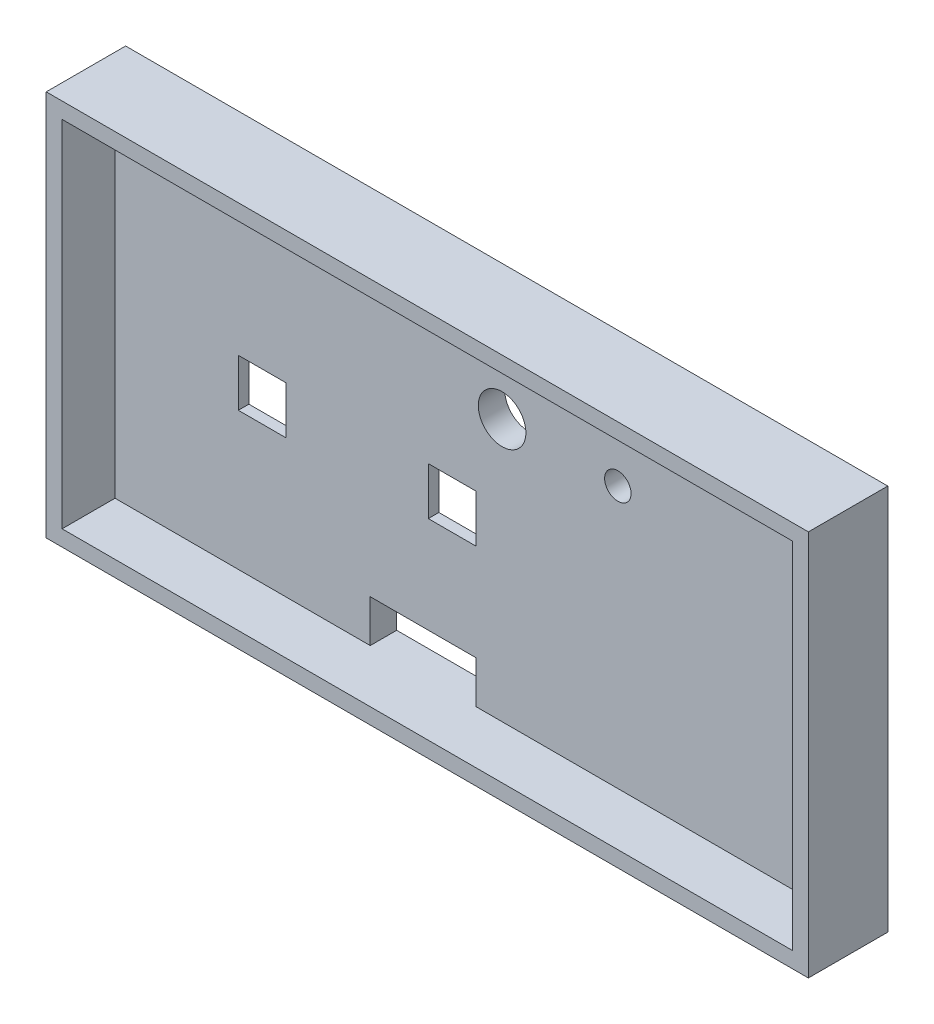
from build123d import *

# Parameters (mm, degrees)
ESQUISSE1_W              = 137
ESQUISSE1_H              = 66
BOSS_EXTRU_2_DEPTH       = 15
ESQUISSE3_W              = 131
ESQUISSE3_H              = 60
ENL_V_MAT_EXTRU_1_DEPTH  = 10
ESQUISSE5_W              = 12
ESQUISSE5_H              = 12
ENL_V_MAT_EXTRU_2_DEPTH  = 10
ESQUISSE6_W              = 12
ESQUISSE6_H              = 12
ENL_V_MAT_EXTRU_3_DEPTH  = 10
ESQUISSE7_W              = 15
ESQUISSE7_H              = 3
ENL_V_MAT_EXTRU_4_DEPTH  = 10
ESQUISSE8_R              = 4.5
ENL_V_MAT_EXTRU_5_DEPTH  = 10
ESQUISSE10_W             = 3
ESQUISSE10_H             = 8
BOSS_EXTRU_3_DEPTH       = 4
ESQUISSE12_W             = 2
ESQUISSE12_H             = 6
ENL_V_MAT_EXTRU_6_DEPTH  = 4
ESQUISSE13_W             = 3
ESQUISSE13_H             = 8
BOSS_EXTRU_4_DEPTH       = 4
ESQUISSE14_W             = 2
ESQUISSE14_H             = 6
ENL_V_MAT_EXTRU_7_DEPTH  = 4
ESQUISSE16_W             = 3
ESQUISSE16_H             = 8
BOSS_EXTRU_5_DEPTH       = 4
ESQUISSE17_W             = 3
ESQUISSE17_H             = 8
BOSS_EXTRU_6_DEPTH       = 4
ESQUISSE19_W             = 2
ESQUISSE19_H             = 6
ENL_V_MAT_EXTRU_9_DEPTH  = 3
ESQUISSE20_W             = 2
ESQUISSE20_H             = 6
ENL_V_MAT_EXTRU_10_DEPTH = 3
ESQUISSE21_R             = 1.5
ENL_V_MAT_EXTRU_12_DEPTH = 21
ESQUISSE22_W             = 3
ESQUISSE22_H             = 8
ENL_V_MAT_EXTRU_13_DEPTH = 4
ESQUISSE23_W             = 3
ESQUISSE23_H             = 8
ENL_V_MAT_EXTRU_14_DEPTH = 4
ESQUISSE24_W             = 3
ESQUISSE24_H             = 8
ENL_V_MAT_EXTRU_15_DEPTH = 4
ESQUISSE25_W             = 3
ESQUISSE25_H             = 8
ENL_V_MAT_EXTRU_16_DEPTH = 4
ESQUISSE28_W             = 12
ESQUISSE28_H             = 12
BOSS_EXTRU_7_DEPTH       = 5
ESQUISSE30_W             = 9
ESQUISSE30_H             = 9
ENL_V_MAT_EXTRU_17_DEPTH = 2.5
ESQUISSE32_W             = 9
ESQUISSE32_H             = 9
ENL_V_MAT_EXTRU_18_DEPTH = 8.5
ESQUISSE33_W             = 16
ESQUISSE33_H             = 16
ENL_V_MAT_EXTRU_19_DEPTH = 3
ESQUISSE34_W             = 16
ESQUISSE34_H             = 16
ENL_V_MAT_EXTRU_20_DEPTH = 3
ESQUISSE35_W             = 9
ESQUISSE35_H             = 9
ENL_V_MAT_EXTRU_21_DEPTH = 3
ESQUISSE36_W             = 12
ESQUISSE36_H             = 12
BOSS_EXTRU_8_DEPTH       = 5
ESQUISSE37_R             = 2.5
ENL_V_MAT_EXTRU_22_DEPTH = 5
ESQUISSE39_W             = 3
ESQUISSE39_H             = 60
ENL_V_MAT_EXTRU_23_DEPTH = 10
ESQUISSE40_W             = 5
ESQUISSE40_H             = 66
BOSS_EXTRU_9_DEPTH       = 7
ESQUISSE41_W             = 3
ESQUISSE41_H             = 66
BOSS_EXTRU_10_DEPTH      = 10
ESQUISSE42_W             = 4
ESQUISSE42_H             = 3
BOSS_EXTRU_11_DEPTH      = 10
ESQUISSE43_W             = 4
ESQUISSE43_H             = 3
BOSS_EXTRU_12_DEPTH      = 10
ESQUISSE44_W             = 20
ESQUISSE44_H             = 8
ENL_V_MAT_EXTRU_24_DEPTH = 10
ESQUISSE46_W             = 138
ESQUISSE46_H             = 3
ENL_V_MAT_EXTRU_25_DEPTH = 10
ESQUISSE47_W             = 141
ESQUISSE47_H             = 5
BOSS_EXTRU_13_DEPTH      = 7
ESQUISSE48_W             = 141
ESQUISSE48_H             = 3.004636282
BOSS_EXTRU_14_DEPTH      = 10
ESQUISSE49_W             = 3
ESQUISSE49_H             = 3.995363718
BOSS_EXTRU_15_DEPTH      = 10
ESQUISSE50_W             = 3
ESQUISSE50_H             = 15
BOSS_EXTRU_16_DEPTH      = 7


with BuildPart() as part:
    # Esquisse1 → Boss.-Extru.2 (new body)
    with BuildSketch(Plane.XY):
        with Locations((68.5, 33)):
            Rectangle(ESQUISSE1_W, ESQUISSE1_H)
    extrude(amount=BOSS_EXTRU_2_DEPTH)

    # Esquisse3 → Enlèv. mat.-Extru.1 (cut)
    with BuildSketch(Plane.XY.offset(15)):
        with Locations((68.5, 33)):
            Rectangle(ESQUISSE3_W, ESQUISSE3_H)
    extrude(amount=-ENL_V_MAT_EXTRU_1_DEPTH, mode=Mode.SUBTRACT)

    # Esquisse5 → Enlèv. mat.-Extru.2 (cut)
    with BuildSketch(Plane(origin=(0, 0, 0), x_dir=(-1, 0, 0), z_dir=(0, 0, -1))):
        with Locations((-14.887820014, 52.506524993)):
            Rectangle(ESQUISSE5_W, ESQUISSE5_H)
    extrude(amount=-ENL_V_MAT_EXTRU_2_DEPTH, mode=Mode.SUBTRACT)

    # Esquisse6 → Enlèv. mat.-Extru.3 (cut)
    with BuildSketch(Plane(origin=(0, 0, 0), x_dir=(-1, 0, 0), z_dir=(0, 0, -1))):
        with Locations((-42.758546676, 52.506524993)):
            Rectangle(ESQUISSE6_W, ESQUISSE6_H)
    extrude(amount=-ENL_V_MAT_EXTRU_3_DEPTH, mode=Mode.SUBTRACT)

    # Esquisse7 → Enlèv. mat.-Extru.4 (cut)
    with BuildSketch(Plane(origin=(0, 0, 0), x_dir=(-1, 0, 0), z_dir=(0, 0, -1))):
        with Locations((-55.331883335, 4.5)):
            Rectangle(ESQUISSE7_W, ESQUISSE7_H)
    extrude(amount=-ENL_V_MAT_EXTRU_4_DEPTH, mode=Mode.SUBTRACT)

    # Esquisse8 → Enlèv. mat.-Extru.5 (cut)
    with BuildSketch(Plane(origin=(0, 0, 0), x_dir=(-1, 0, 0), z_dir=(0, 0, -1))):
        with Locations((-69.128546676, 52.506524993)):
            Circle(ESQUISSE8_R)
    extrude(amount=-ENL_V_MAT_EXTRU_5_DEPTH, mode=Mode.SUBTRACT)

    # Esquisse10 → Boss.-Extru.3 (add)
    with BuildSketch(Plane.XY.offset(5)):
        with Locations((7.387820014, 52.506524993)):
            Rectangle(ESQUISSE10_W, ESQUISSE10_H)
    extrude(amount=BOSS_EXTRU_3_DEPTH)

    # Esquisse12 → Enlèv. mat.-Extru.6 (cut)
    with BuildSketch(Plane(origin=(8.887820014, 0, 0), x_dir=(0, 0, -1), z_dir=(1, 0, 0))):
        with Locations((-7, 52.506524993)):
            Rectangle(ESQUISSE12_W, ESQUISSE12_H)
    extrude(amount=-ENL_V_MAT_EXTRU_6_DEPTH, mode=Mode.SUBTRACT)

    # Esquisse13 → Boss.-Extru.4 (add)
    with BuildSketch(Plane.XY.offset(5)):
        with Locations((22.387820014, 52.506524993)):
            Rectangle(ESQUISSE13_W, ESQUISSE13_H)
    extrude(amount=BOSS_EXTRU_4_DEPTH)

    # Esquisse14 → Enlèv. mat.-Extru.7 (cut)
    with BuildSketch(Plane(origin=(23.887820014, 0, 0), x_dir=(0, 0, -1), z_dir=(1, 0, 0))):
        with Locations((-7, 52.506524993)):
            Rectangle(ESQUISSE14_W, ESQUISSE14_H)
    extrude(amount=-ENL_V_MAT_EXTRU_7_DEPTH, mode=Mode.SUBTRACT)

    # Esquisse16 → Boss.-Extru.5 (add)
    with BuildSketch(Plane.XY.offset(5)):
        with Locations((35.258546676, 52.506524993)):
            Rectangle(ESQUISSE16_W, ESQUISSE16_H)
    extrude(amount=BOSS_EXTRU_5_DEPTH)

    # Esquisse17 → Boss.-Extru.6 (add)
    with BuildSketch(Plane.XY.offset(5)):
        with Locations((50.258546676, 52.506524993)):
            Rectangle(ESQUISSE17_W, ESQUISSE17_H)
    extrude(amount=BOSS_EXTRU_6_DEPTH)

    # Esquisse19 → Enlèv. mat.-Extru.9 (cut)
    with BuildSketch(Plane(origin=(36.758546676, 0, 0), x_dir=(0, 0, -1), z_dir=(1, 0, 0))):
        with Locations((-7, 52.506524993)):
            Rectangle(ESQUISSE19_W, ESQUISSE19_H)
    extrude(amount=-ENL_V_MAT_EXTRU_9_DEPTH, mode=Mode.SUBTRACT)

    # Esquisse20 → Enlèv. mat.-Extru.10 (cut)
    with BuildSketch(Plane(origin=(51.758546676, 0, 0), x_dir=(0, 0, -1), z_dir=(1, 0, 0))):
        with Locations((-7, 52.506524993)):
            Rectangle(ESQUISSE20_W, ESQUISSE20_H)
    extrude(amount=-ENL_V_MAT_EXTRU_10_DEPTH, mode=Mode.SUBTRACT)

    # Esquisse21 → Enlèv. mat.-Extru.12 (cut)
    with BuildSketch(Plane(origin=(0, 0, 0), x_dir=(-1, 0, 0), z_dir=(0, 0, -1))):
        with Locations((-90.998546676, 52.506524993)):
            Circle(ESQUISSE21_R)
    extrude(amount=-ENL_V_MAT_EXTRU_12_DEPTH, mode=Mode.SUBTRACT)

    # Esquisse22 → Enlèv. mat.-Extru.13 (cut)
    with BuildSketch(Plane.XY.offset(9)):
        with Locations((50.258546676, 52.506524993)):
            Rectangle(ESQUISSE22_W, ESQUISSE22_H)
    extrude(amount=-ENL_V_MAT_EXTRU_13_DEPTH, mode=Mode.SUBTRACT)

    # Esquisse23 → Enlèv. mat.-Extru.14 (cut)
    with BuildSketch(Plane.XY.offset(9)):
        with Locations((35.258546676, 52.506524993)):
            Rectangle(ESQUISSE23_W, ESQUISSE23_H)
    extrude(amount=-ENL_V_MAT_EXTRU_14_DEPTH, mode=Mode.SUBTRACT)

    # Esquisse24 → Enlèv. mat.-Extru.15 (cut)
    with BuildSketch(Plane.XY.offset(9)):
        with Locations((22.387820014, 52.506524993)):
            Rectangle(ESQUISSE24_W, ESQUISSE24_H)
    extrude(amount=-ENL_V_MAT_EXTRU_15_DEPTH, mode=Mode.SUBTRACT)

    # Esquisse25 → Enlèv. mat.-Extru.16 (cut)
    with BuildSketch(Plane.XY.offset(9)):
        with Locations((7.387820014, 52.506524993)):
            Rectangle(ESQUISSE25_W, ESQUISSE25_H)
    extrude(amount=-ENL_V_MAT_EXTRU_16_DEPTH, mode=Mode.SUBTRACT)

    # Esquisse28 → Boss.-Extru.7 (add)
    with BuildSketch(Plane(origin=(0, 0, 0), x_dir=(-1, 0, 0), z_dir=(0, 0, -1))):
        with Locations((-14.887820014, 52.506524993)):
            Rectangle(ESQUISSE28_W, ESQUISSE28_H)
    extrude(amount=-BOSS_EXTRU_7_DEPTH)

    # Esquisse30 → Enlèv. mat.-Extru.17 (cut)
    with BuildSketch(Plane.XY.offset(5)):
        with Locations((23.793387087, 33.541365404)):
            Rectangle(ESQUISSE30_W, ESQUISSE30_H)
    extrude(amount=-ENL_V_MAT_EXTRU_17_DEPTH, mode=Mode.SUBTRACT)

    # Esquisse32 → Enlèv. mat.-Extru.18 (cut)
    with BuildSketch(Plane.XY.offset(5)):
        with Locations((23.793387087, 33.541365404)):
            Rectangle(ESQUISSE32_W, ESQUISSE32_H)
    extrude(amount=-ENL_V_MAT_EXTRU_18_DEPTH, mode=Mode.SUBTRACT)

    # Esquisse33 → Enlèv. mat.-Extru.19 (cut)
    with BuildSketch(Plane(origin=(0, 0, 0), x_dir=(-1, 0, 0), z_dir=(0, 0, -1))):
        with Locations((-23.76482076, 33.512799076)):
            Rectangle(ESQUISSE33_W, ESQUISSE33_H)
    extrude(amount=-ENL_V_MAT_EXTRU_19_DEPTH, mode=Mode.SUBTRACT)

    # Esquisse34 → Enlèv. mat.-Extru.20 (cut)
    with BuildSketch(Plane(origin=(0, 0, 0), x_dir=(-1, 0, 0), z_dir=(0, 0, -1))):
        with Locations((-59.43745725, 33.512799076)):
            Rectangle(ESQUISSE34_W, ESQUISSE34_H)
    extrude(amount=-ENL_V_MAT_EXTRU_20_DEPTH, mode=Mode.SUBTRACT)

    # Esquisse35 → Enlèv. mat.-Extru.21 (cut)
    with BuildSketch(Plane(origin=(0, 0, 3), x_dir=(-1, 0, 0), z_dir=(0, 0, -1))):
        with Locations((-59.688365981, 33.763707808)):
            Rectangle(ESQUISSE35_W, ESQUISSE35_H)
    extrude(amount=-ENL_V_MAT_EXTRU_21_DEPTH, mode=Mode.SUBTRACT)

    # Esquisse36 → Boss.-Extru.8 (add)
    with BuildSketch(Plane(origin=(0, 0, 0), x_dir=(-1, 0, 0), z_dir=(0, 0, -1))):
        with Locations((-42.758546676, 52.506524993)):
            Rectangle(ESQUISSE36_W, ESQUISSE36_H)
    extrude(amount=-BOSS_EXTRU_8_DEPTH)

    # Esquisse37 → Enlèv. mat.-Extru.22 (cut)
    with BuildSketch(Plane(origin=(0, 0, 0), x_dir=(-1, 0, 0), z_dir=(0, 0, -1))):
        with Locations((-90.998546676, 52.506524993)):
            Circle(ESQUISSE37_R)
    extrude(amount=-ENL_V_MAT_EXTRU_22_DEPTH, mode=Mode.SUBTRACT)

    # Esquisse39 → Enlèv. mat.-Extru.23 (cut)
    with BuildSketch(Plane.XY.offset(15)):
        with Locations((1.5, 33)):
            Rectangle(ESQUISSE39_W, ESQUISSE39_H)
    extrude(amount=-ENL_V_MAT_EXTRU_23_DEPTH, mode=Mode.SUBTRACT)

    # Esquisse40 → Boss.-Extru.9 (add)
    with BuildSketch(Plane.ZY):
        with Locations((2.5, 33)):
            Rectangle(ESQUISSE40_W, ESQUISSE40_H)
    extrude(amount=BOSS_EXTRU_9_DEPTH)

    # Esquisse41 → Boss.-Extru.10 (add)
    with BuildSketch(Plane.XY.offset(5)):
        with Locations((-5.5, 33)):
            Rectangle(ESQUISSE41_W, ESQUISSE41_H)
    extrude(amount=BOSS_EXTRU_10_DEPTH)

    # Esquisse42 → Boss.-Extru.11 (add)
    with BuildSketch(Plane.XY.offset(5)):
        with Locations((-2, 1.5)):
            Rectangle(ESQUISSE42_W, ESQUISSE42_H)
    extrude(amount=BOSS_EXTRU_11_DEPTH)

    # Esquisse43 → Boss.-Extru.12 (add)
    with BuildSketch(Plane.XY.offset(5)):
        with Locations((-2, 64.5)):
            Rectangle(ESQUISSE43_W, ESQUISSE43_H)
    extrude(amount=BOSS_EXTRU_12_DEPTH)

    # Esquisse44 → Enlèv. mat.-Extru.24 (cut)
    with BuildSketch(Plane.XY.offset(5)):
        with Locations((54.216853372, 7)):
            Rectangle(ESQUISSE44_W, ESQUISSE44_H)
    extrude(amount=-ENL_V_MAT_EXTRU_24_DEPTH, mode=Mode.SUBTRACT)

    # Esquisse46 → Enlèv. mat.-Extru.25 (cut)
    with BuildSketch(Plane.XY.offset(5)):
        with Locations((65, 64.5)):
            Rectangle(ESQUISSE46_W, ESQUISSE46_H)
    extrude(amount=ENL_V_MAT_EXTRU_25_DEPTH, mode=Mode.SUBTRACT)

    # Esquisse47 → Boss.-Extru.13 (add)
    with BuildSketch(Plane(origin=(0, 66, 0), x_dir=(1, 0, 0), z_dir=(0, 1, 0))):
        with Locations((63.5, -2.5)):
            Rectangle(ESQUISSE47_W, ESQUISSE47_H)
    extrude(amount=BOSS_EXTRU_13_DEPTH)

    # Esquisse48 → Boss.-Extru.14 (add)
    with BuildSketch(Plane.XY.offset(5)):
        with Locations((63.5, 71.497681859)):
            Rectangle(ESQUISSE48_W, ESQUISSE48_H)
    extrude(amount=BOSS_EXTRU_14_DEPTH)

    # Esquisse49 → Boss.-Extru.15 (add)
    with BuildSketch(Plane.XY.offset(5)):
        with Locations((-5.5, 67.997681859)):
            Rectangle(ESQUISSE49_W, ESQUISSE49_H)
    extrude(amount=BOSS_EXTRU_15_DEPTH)

    # Esquisse50 → Boss.-Extru.16 (add)
    with BuildSketch(Plane(origin=(0, 66, 0), x_dir=(1, 0, 0), z_dir=(0, 1, 0))):
        with Locations((135.5, -7.5)):
            Rectangle(ESQUISSE50_W, ESQUISSE50_H)
    extrude(amount=BOSS_EXTRU_16_DEPTH)


solid = part.part
